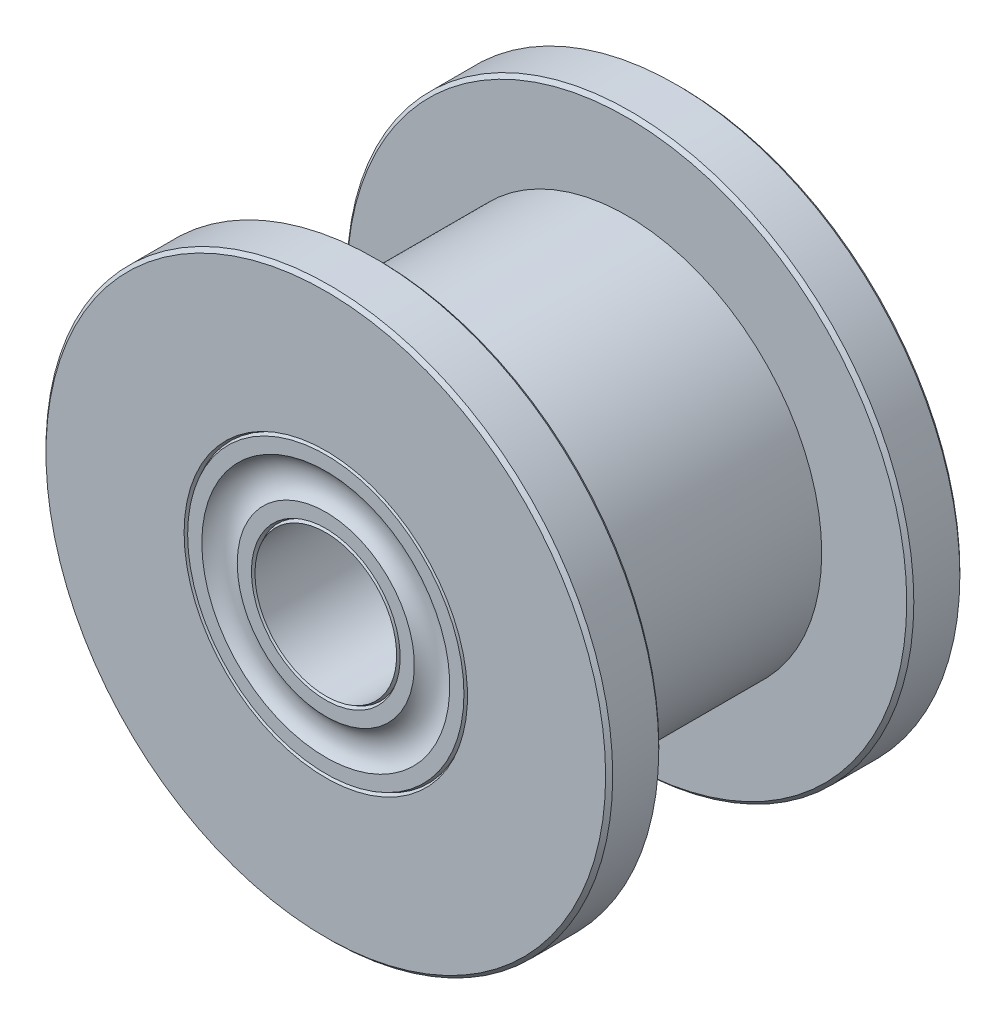
from build123d import *

# Parameters (mm, degrees)
CROQUIS1_R              = 5.5
CROQUIS1_R_2            = 2
SALIENTE_EXTRUIR1_DEPTH = 10
CROQUIS2_R              = 8
CROQUIS2_R_2            = 2
SALIENTE_EXTRUIR3_DEPTH = 1.5
SALIENTE_EXTRUIR5_START = 8.5
CROQUIS2_3_R            = 8
CROQUIS2_3_R_2          = 2
SALIENTE_EXTRUIR5_DEPTH = 1.5
CHAFL_N1_SIZE           = 0.1


with BuildPart() as part:
    # Croquis1 → Saliente-Extruir1 (new body)
    with BuildSketch(Plane.XY):
        Circle(CROQUIS1_R)
        Circle(CROQUIS1_R_2, mode=Mode.SUBTRACT)
    extrude(amount=SALIENTE_EXTRUIR1_DEPTH)

    # Croquis2 → Saliente-Extruir3 (add)
    with BuildSketch(Plane.XY):
        Circle(CROQUIS2_R)
        Circle(CROQUIS2_R_2, mode=Mode.SUBTRACT)
    extrude(amount=SALIENTE_EXTRUIR3_DEPTH)

    # Croquis2_3 → Saliente-Extruir5 (add)
    with BuildSketch(Plane.XY.offset(SALIENTE_EXTRUIR5_START)):
        Circle(CROQUIS2_3_R)
        Circle(CROQUIS2_3_R_2, mode=Mode.SUBTRACT)
    extrude(amount=SALIENTE_EXTRUIR5_DEPTH)

    # Chaflán1
    chafl_n1_edges = [part.edges().sort_by_distance(p)[0] for p in [
        (-8, 0, 0),
        (-8, 0, 1.5),
        (-8, 0, 8.5),
        (-8, 0, 10),
    ]]
    chamfer(chafl_n1_edges, length=CHAFL_N1_SIZE)

    # Croquis3 → Cortar-Revolución1 (revolve, cut)
    with BuildSketch(Plane(origin=(0, 0, 0), x_dir=(1, 0, 0), z_dir=(0, 1, 0))):
        with BuildLine():
            Line((-2, 0), (-2.05, -0.1))
            Line((-2.05, -0.1), (-2.1, 0))
            Line((-2.1, 0), (-2.5, 0))
            ThreePointArc((-2.5, 0), (-3, -0.210102051), (-3.5, 0))
            Line((-3.5, 0), (-3.9, 0))
            Line((-3.9, 0), (-3.95, -0.1))
            Line((-3.95, -0.1), (-4, 0))
            Line((-4, 0), (-4, 0.1))
            Line((-4, 0.1), (-2, 0.1))
            Line((-2, 0.1), (-2, 0))
        make_face()
        with BuildLine():
            Line((-2, -10.1), (-2, -10))
            Line((-2, -10), (-2.05, -9.9))
            Line((-2.05, -9.9), (-2.1, -10))
            Line((-2.1, -10), (-2.5, -10))
            ThreePointArc((-2.5, -10), (-3, -9.789897949), (-3.5, -10))
            Line((-3.5, -10), (-3.9, -10))
            Line((-3.9, -10), (-3.95, -9.9))
            Line((-3.95, -9.9), (-4, -10))
            Line((-4, -10), (-4, -10.1))
            Line((-4, -10.1), (-2, -10.1))
        make_face()
    revolve(axis=Axis((0, 0, 0), (0, 0, 1)), mode=Mode.SUBTRACT)


solid = part.part
